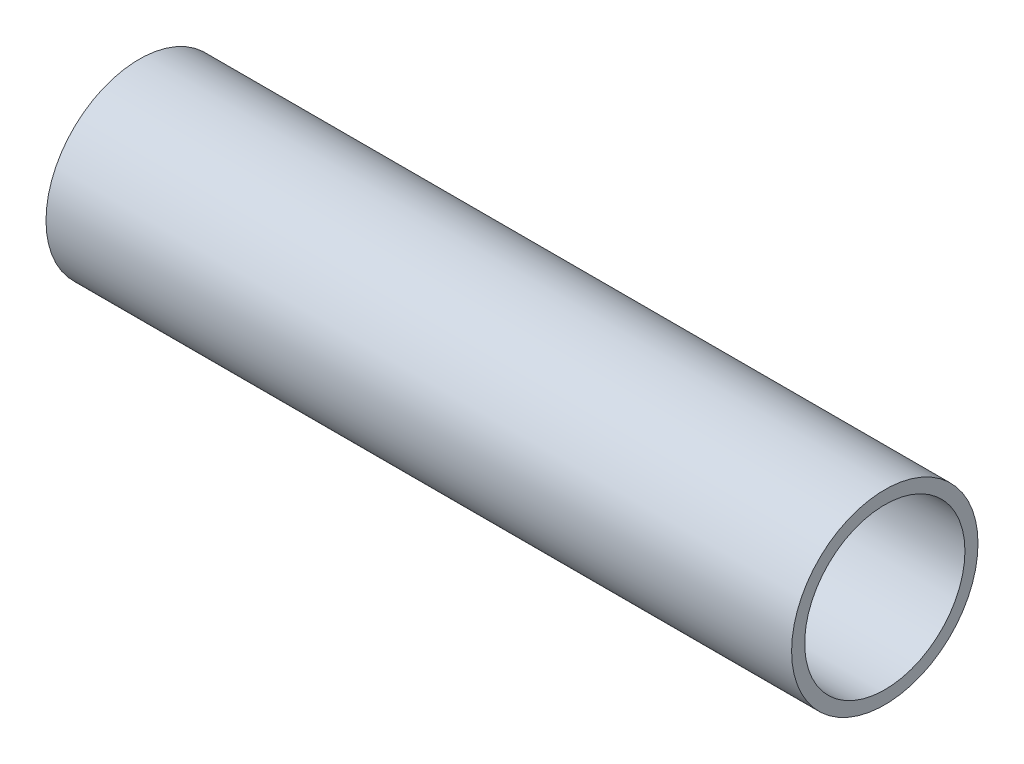
from build123d import *

# Parameters (mm, degrees)
SKETCH1_R           = 6.35
SKETCH1_R_2         = 5.461
BOSS_EXTRUDE1_DEPTH = 50.8


with BuildPart() as part:
    # Sketch1 → Boss-Extrude1 (new body)
    with BuildSketch(Plane(origin=(0, 0, 0), x_dir=(0, 0, -1), z_dir=(1, 0, 0))):
        Circle(SKETCH1_R)
        Circle(SKETCH1_R_2, mode=Mode.SUBTRACT)
    extrude(amount=BOSS_EXTRUDE1_DEPTH)


solid = part.part
